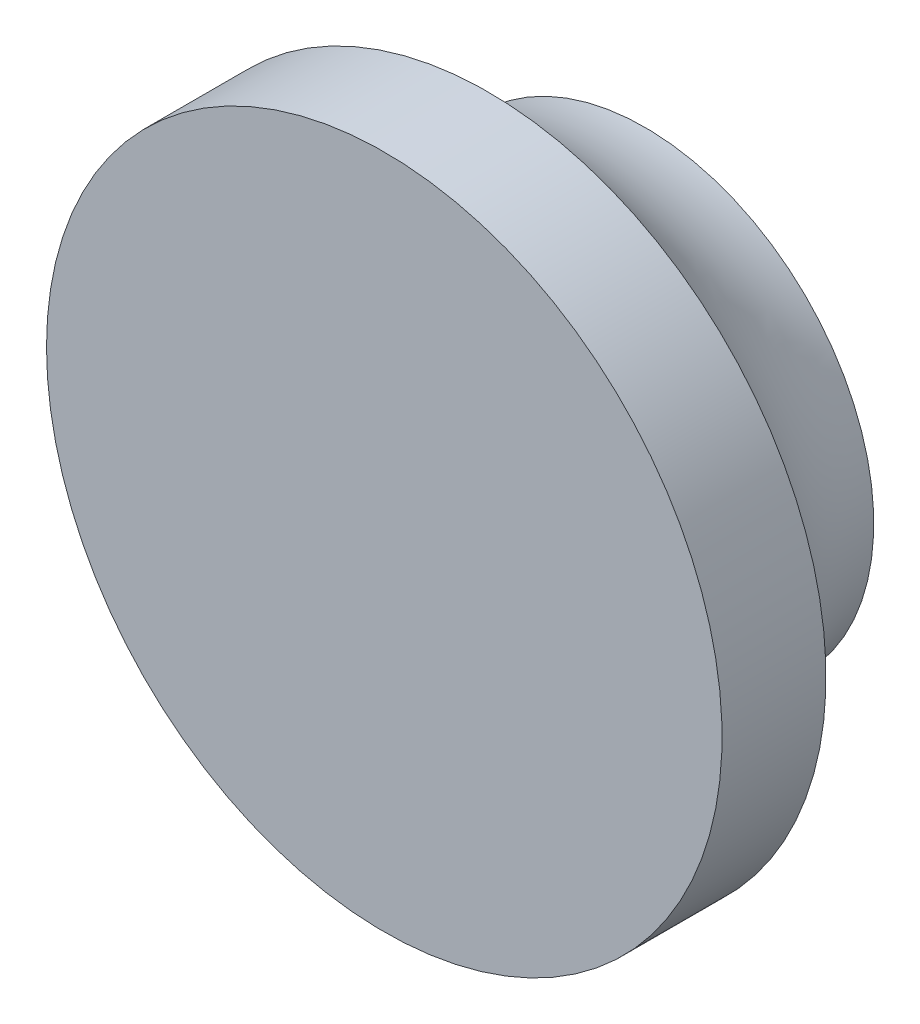
from build123d import *


with BuildPart() as part:
    # Sketch4 → Revolve1 (revolve)
    with BuildSketch(Plane.ZY.offset(-206.339551417)):
        with BuildLine():
            Line((286.793509682, -87.096793579), (286.793509682, -95.896793579))
            Line((286.793509682, -95.896793579), (296.83197122, -95.896793579))
            Line((296.83197122, -95.896793579), (296.83197122, -82.896793579))
            Line((296.83197122, -82.896793579), (292.83197122, -82.896793579))
            ThreePointArc((292.83197122, -82.896793579), (290.408852958, -85.85384178), (286.793509682, -87.096793579))
        make_face()
    revolve(axis=Axis((206.339551417, -95.896793579, 276.164391965), (0, 0, 1)))


solid = part.part
